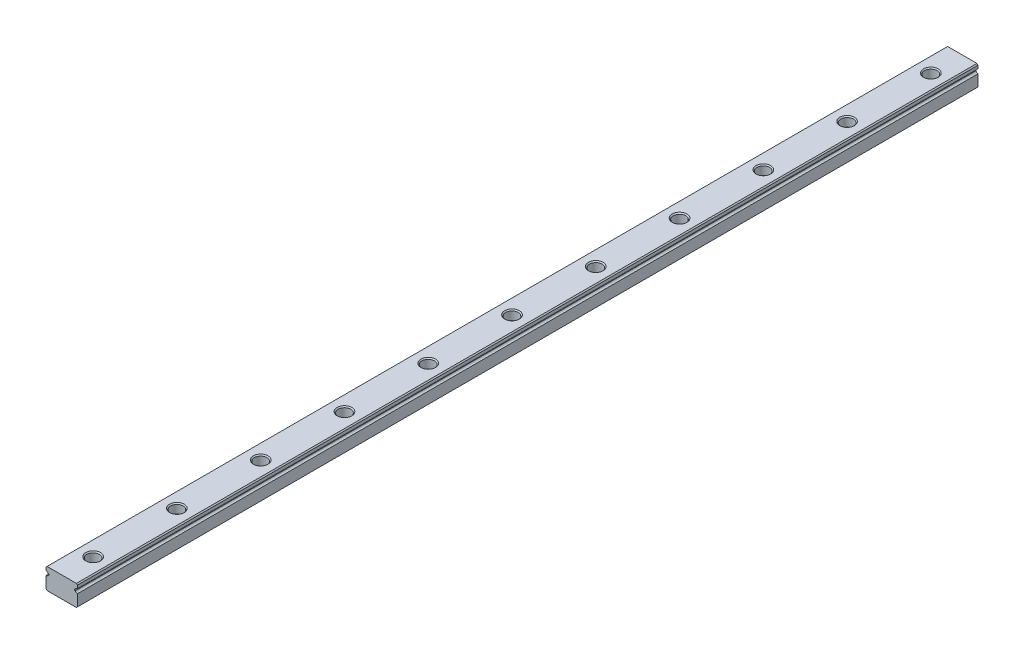
from build123d import *

# Parameters (mm, degrees)
BOSS_EXTRUDE1_DEPTH = 430
CHAMFER1_SIZE       = 0.5
LPATTERN1_COUNT     = 11
LPATTERN1_PITCH     = 40


with BuildPart() as part:
    # Sketch1 → Boss-Extrude1 (new body)
    with BuildSketch(Plane.XY):
        with BuildLine():
            Line((-7.5, 10), (7.5, 10))
            Line((7.5, 10), (7.5, 8.25))
            Line((7.5, 8.25), (7.5, 8.030776406))
            ThreePointArc((7.5, 8.030776406), (6.865647614, 7.812463569), (6.5, 7.25))
            Line((6.5, 7.25), (6, 7.25))
            Line((6, 7.25), (6, 6.75))
            Line((6, 6.75), (6.5, 6.75))
            ThreePointArc((6.5, 6.75), (6.865647614, 6.187536431), (7.5, 5.969223594))
            Line((7.5, 5.969223594), (7.5, 5.75))
            Line((7.5, 5.75), (7.5, 0))
            Line((7.5, 0), (-7.5, 0))
            Line((-7.5, 0), (-7.5, 5.75))
            Line((-7.5, 5.75), (-7.5, 5.969223594))
            ThreePointArc((-7.5, 5.969223594), (-6.865647614, 6.187536431), (-6.5, 6.75))
            Line((-6.5, 6.75), (-6, 6.75))
            Line((-6, 6.75), (-6, 7.25))
            Line((-6, 7.25), (-6.5, 7.25))
            ThreePointArc((-6.5, 7.25), (-6.865647614, 7.812463569), (-7.5, 8.030776406))
            Line((-7.5, 8.030776406), (-7.5, 8.25))
            Line((-7.5, 8.25), (-7.5, 10))
        make_face()
    extrude(amount=BOSS_EXTRUDE1_DEPTH)

    # Chamfer1
    chamfer1_edges = [part.edges().sort_by_distance(p)[0] for p in [
        (-7.5, 10, 215),
        (7.5, 10, 215),
        (7.5, 0, 215),
        (-7.5, 0, 215),
    ]]
    chamfer(chamfer1_edges, length=CHAMFER1_SIZE)

    # Sketch3 → M3 六角承窩頭蓋螺釘的柱孔1 (revolve, cut)
    with BuildSketch(Plane(origin=(0, 10, 15), x_dir=(0, 0, 1), z_dir=(1, 0, 0))):
        Polygon((0, 0), (0, 10), (2, 10), (1.75, 9.75), (1.75, 4.5), (3, 4.5), (3, 0.5), (3.5, 0), align=None)
    hole_wizard_m3_1 = revolve(axis=Axis((0, 16.35, 15), (0, -1, 0)), mode=Mode.SUBTRACT)

    # LPattern1: M3 六角承窩頭蓋螺釘的柱孔1 ×11
    with Locations(*[(0, 0, i * LPATTERN1_PITCH) for i in range(1, LPATTERN1_COUNT)]):
        add(hole_wizard_m3_1, mode=Mode.SUBTRACT)


solid = part.part
